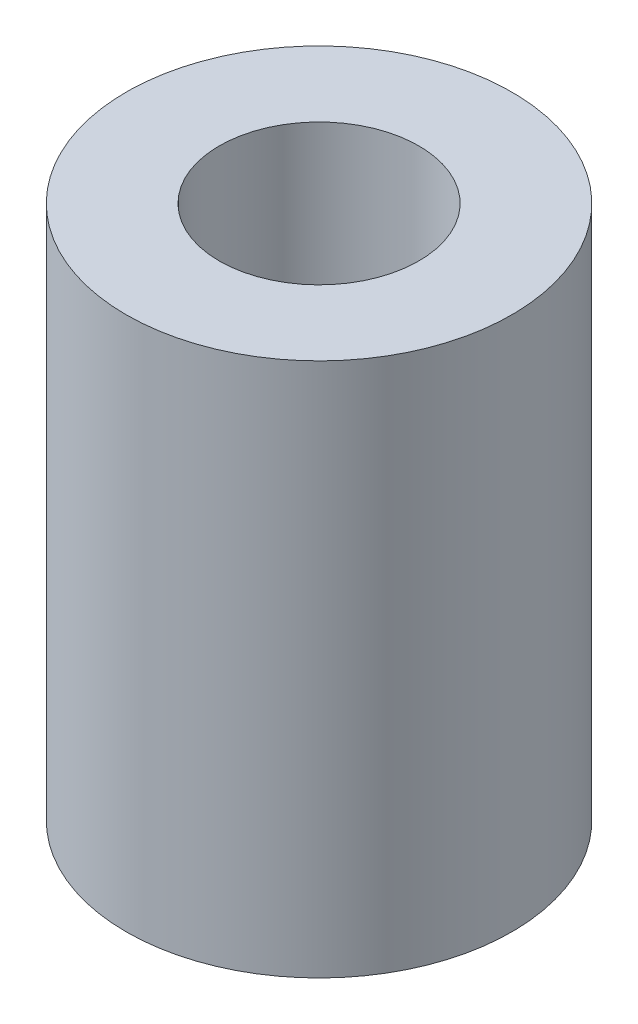
from build123d import *

# Parameters (mm, degrees)
SKETCH1_R           = 6.2611
SKETCH1_R_2         = 3.2385
BOSS_EXTRUDE1_DEPTH = 17.3482


with BuildPart() as part:
    # Sketch1 → Boss-Extrude1 (new body)
    with BuildSketch(Plane(origin=(0, 0, 0), x_dir=(1, 0, 0), z_dir=(0, 1, 0))):
        Circle(SKETCH1_R)
        Circle(SKETCH1_R_2, mode=Mode.SUBTRACT)
    extrude(amount=BOSS_EXTRUDE1_DEPTH)


solid = part.part
